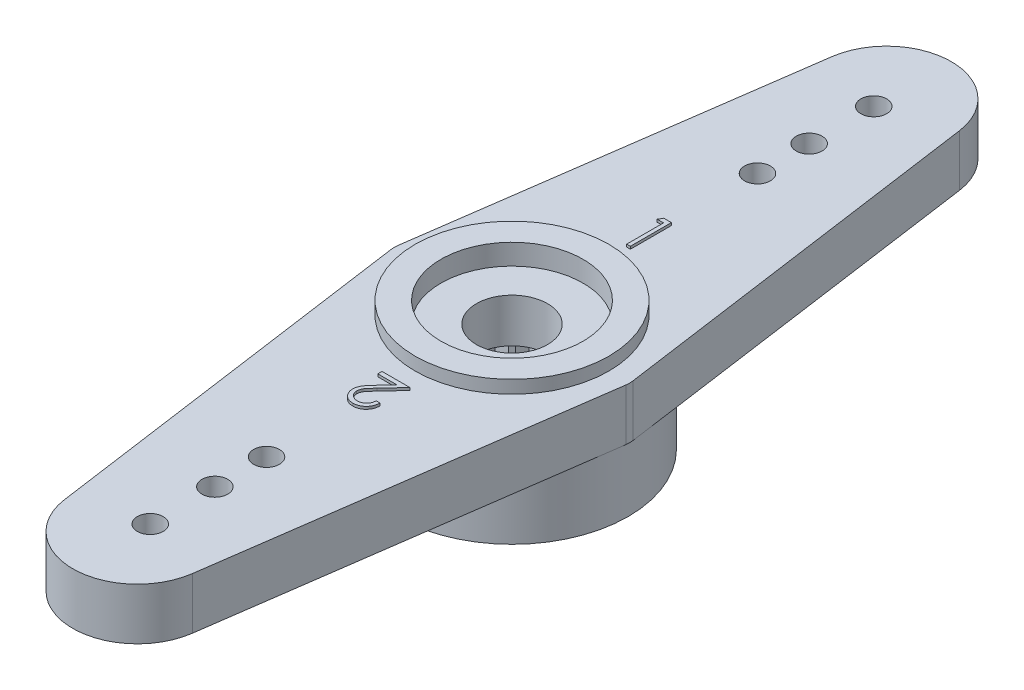
from build123d import *

# Parameters (mm, degrees)
SKETCH1_R           = 0.5
SKETCH1_R_2         = 1.375
BOSS_EXTRUDE1_DEPTH = 2
SKETCH2_R           = 3.75
SKETCH2_R_2         = 2.75
BOSS_EXTRUDE2_DEPTH = 0.5
SKETCH3_R           = 2.75
SKETCH3_R_2         = 1.375
CUT_EXTRUDE1_DEPTH  = 0.8
SKETCH4_R           = 4.5
SKETCH4_R_2         = 2.5
BOSS_EXTRUDE3_DEPTH = 2.5
CUT_EXTRUDE3_DEPTH  = 2.5
BOSS_EXTRUDE4_DEPTH = 0.1
FILLET1_R           = 1


with BuildPart() as part:
    # Sketch1 → Boss-Extrude1 (new body)
    with BuildSketch(Plane(origin=(0, 0, 0), x_dir=(1, 0, 0), z_dir=(0, 1, 0))):
        with BuildLine():
            Line((-4, 4), (-2.475677962, 14.847877319))
            ThreePointArc((-2.475677962, 14.847877319), (0, 17), (2.475677962, 14.847877319))
            Line((2.475677962, 14.847877319), (4, 4))
            Line((4, 4), (4.562072005, 0))
            Line((4.562072005, 0), (4, -4))
            Line((4, -4), (2.475677962, -14.847877319))
            ThreePointArc((2.475677962, -14.847877319), (0, -17), (-2.475677962, -14.847877319))
            Line((-2.475677962, -14.847877319), (-4, -4))
            Line((-4, -4), (-4.562072005, 0))
            Line((-4.562072005, 0), (-4, 4))
        make_face()
        with Locations((0, 14)):
            Circle(SKETCH1_R, mode=Mode.SUBTRACT)
        with Locations((0, 11.5)):
            Circle(SKETCH1_R, mode=Mode.SUBTRACT)
        with Locations((0, 9.5)):
            Circle(SKETCH1_R, mode=Mode.SUBTRACT)
        with Locations((0, -14)):
            Circle(SKETCH1_R, mode=Mode.SUBTRACT)
        with Locations((0, -11.5)):
            Circle(SKETCH1_R, mode=Mode.SUBTRACT)
        with Locations((0, -9.5)):
            Circle(SKETCH1_R, mode=Mode.SUBTRACT)
        Circle(SKETCH1_R_2, mode=Mode.SUBTRACT)
    extrude(amount=BOSS_EXTRUDE1_DEPTH)

    # Sketch2 → Boss-Extrude2 (add)
    with BuildSketch(Plane(origin=(0, 2, 0), x_dir=(1, 0, 0), z_dir=(0, 1, 0))):
        Circle(SKETCH2_R)
        Circle(SKETCH2_R_2, mode=Mode.SUBTRACT)
    extrude(amount=BOSS_EXTRUDE2_DEPTH)

    # Sketch3 → Cut-Extrude1 (cut)
    with BuildSketch(Plane(origin=(0, 2.5, 0), x_dir=(1, 0, 0), z_dir=(0, 1, 0))):
        Circle(SKETCH3_R)
        Circle(SKETCH3_R_2, mode=Mode.SUBTRACT)
    extrude(amount=-CUT_EXTRUDE1_DEPTH, mode=Mode.SUBTRACT)

    # Sketch4 → Boss-Extrude3 (add)
    with BuildSketch(Plane.XZ):
        Circle(SKETCH4_R)
        Circle(SKETCH4_R_2, mode=Mode.SUBTRACT)
    extrude(amount=BOSS_EXTRUDE3_DEPTH)

    # Sketch5 → Cut-Extrude3 (cut)
    with BuildSketch(Plane.XZ.offset(2.5)):
        with BuildLine():
            Line((0.299038106, 2.482050808), (0, 3))
            Line((0, 3), (-0.299038106, 2.482050808))
            ThreePointArc((-0.299038106, 2.482050808), (0, 2.5), (0.299038106, 2.482050808))
        make_face()
        with BuildLine():
            ThreePointArc((-1.051398019, 2.268162738), (-0.772542486, 2.377641291), (-0.482593741, 2.452978451))
            Line((-0.482593741, 2.452978451), (-0.927050983, 2.853169549))
            Line((-0.927050983, 2.853169549), (-1.051398019, 2.268162738))
        make_face()
        with BuildLine():
            Line((0.927050983, 2.853169549), (0.482593741, 2.452978451))
            ThreePointArc((0.482593741, 2.452978451), (0.772542486, 2.377641291), (1.051398019, 2.268162738))
            Line((1.051398019, 2.268162738), (0.927050983, 2.853169549))
        make_face()
        with BuildLine():
            ThreePointArc((-1.70083977, 1.832251096), (-1.469463131, 2.022542486), (-1.216985951, 2.183791473))
            Line((-1.216985951, 2.183791473), (-1.763355757, 2.427050983))
            Line((-1.763355757, 2.427050983), (-1.70083977, 1.832251096))
        make_face()
        with BuildLine():
            Line((1.763355757, 2.427050983), (1.216985951, 2.183791473))
            ThreePointArc((1.216985951, 2.183791473), (1.469463131, 2.022542486), (1.70083977, 1.832251096))
            Line((1.70083977, 1.832251096), (1.763355757, 2.427050983))
        make_face()
        with BuildLine():
            ThreePointArc((-2.183791473, 1.216985951), (-2.022542486, 1.469463131), (-1.832251096, 1.70083977))
            Line((-1.832251096, 1.70083977), (-2.427050983, 1.763355757))
            Line((-2.427050983, 1.763355757), (-2.183791473, 1.216985951))
        make_face()
        with BuildLine():
            Line((2.427050983, 1.763355757), (1.832251096, 1.70083977))
            ThreePointArc((1.832251096, 1.70083977), (2.022542486, 1.469463131), (2.183791473, 1.216985951))
            Line((2.183791473, 1.216985951), (2.427050983, 1.763355757))
        make_face()
        with BuildLine():
            ThreePointArc((-2.452978451, 0.482593741), (-2.377641291, 0.772542486), (-2.268162738, 1.051398019))
            Line((-2.268162738, 1.051398019), (-2.853169549, 0.927050983))
            Line((-2.853169549, 0.927050983), (-2.452978451, 0.482593741))
        make_face()
        with BuildLine():
            Line((2.853169549, 0.927050983), (2.268162738, 1.051398019))
            ThreePointArc((2.268162738, 1.051398019), (2.377641291, 0.772542486), (2.452978451, 0.482593741))
            Line((2.452978451, 0.482593741), (2.853169549, 0.927050983))
        make_face()
        with BuildLine():
            ThreePointArc((-2.482050808, -0.299038106), (-2.5, 0), (-2.482050808, 0.299038106))
            Line((-2.482050808, 0.299038106), (-3, 0))
            Line((-3, 0), (-2.482050808, -0.299038106))
        make_face()
        with BuildLine():
            Line((3, 0), (2.482050808, 0.299038106))
            ThreePointArc((2.482050808, 0.299038106), (2.5, 0), (2.482050808, -0.299038106))
            Line((2.482050808, -0.299038106), (3, 0))
        make_face()
        with BuildLine():
            ThreePointArc((-2.268162738, -1.051398019), (-2.377641291, -0.772542486), (-2.452978451, -0.482593741))
            Line((-2.452978451, -0.482593741), (-2.853169549, -0.927050983))
            Line((-2.853169549, -0.927050983), (-2.268162738, -1.051398019))
        make_face()
        with BuildLine():
            Line((2.853169549, -0.927050983), (2.452978451, -0.482593741))
            ThreePointArc((2.452978451, -0.482593741), (2.377641291, -0.772542486), (2.268162738, -1.051398019))
            Line((2.268162738, -1.051398019), (2.853169549, -0.927050983))
        make_face()
        with BuildLine():
            ThreePointArc((-1.832251096, -1.70083977), (-2.022542486, -1.469463131), (-2.183791473, -1.216985951))
            Line((-2.183791473, -1.216985951), (-2.427050983, -1.763355757))
            Line((-2.427050983, -1.763355757), (-1.832251096, -1.70083977))
        make_face()
        with BuildLine():
            Line((2.427050983, -1.763355757), (2.183791473, -1.216985951))
            ThreePointArc((2.183791473, -1.216985951), (2.022542486, -1.469463131), (1.832251096, -1.70083977))
            Line((1.832251096, -1.70083977), (2.427050983, -1.763355757))
        make_face()
        with BuildLine():
            ThreePointArc((-1.216985951, -2.183791473), (-1.469463131, -2.022542486), (-1.70083977, -1.832251096))
            Line((-1.70083977, -1.832251096), (-1.763355757, -2.427050983))
            Line((-1.763355757, -2.427050983), (-1.216985951, -2.183791473))
        make_face()
        with BuildLine():
            Line((1.763355757, -2.427050983), (1.70083977, -1.832251096))
            ThreePointArc((1.70083977, -1.832251096), (1.469463131, -2.022542486), (1.216985951, -2.183791473))
            Line((1.216985951, -2.183791473), (1.763355757, -2.427050983))
        make_face()
        with BuildLine():
            ThreePointArc((-0.482593741, -2.452978451), (-0.772542486, -2.377641291), (-1.051398019, -2.268162738))
            Line((-1.051398019, -2.268162738), (-0.927050983, -2.853169549))
            Line((-0.927050983, -2.853169549), (-0.482593741, -2.452978451))
        make_face()
        with BuildLine():
            Line((0.927050983, -2.853169549), (1.051398019, -2.268162738))
            ThreePointArc((1.051398019, -2.268162738), (0.772542486, -2.377641291), (0.482593741, -2.452978451))
            Line((0.482593741, -2.452978451), (0.927050983, -2.853169549))
        make_face()
        with BuildLine():
            ThreePointArc((0.299038106, -2.482050808), (0, -2.5), (-0.299038106, -2.482050808))
            Line((-0.299038106, -2.482050808), (0, -3))
            Line((0, -3), (0.299038106, -2.482050808))
        make_face()
    extrude(amount=-CUT_EXTRUDE3_DEPTH, mode=Mode.SUBTRACT)

    # Sketch6 → Boss-Extrude4 (add)
    with BuildSketch(Plane(origin=(0, 2, 0), x_dir=(1, 0, 0), z_dir=(0, 1, 0))):
        Polygon((-0.212111879, 6.0875), (0.081410256, 6.0875), (0.081410256, 4.5), (-0.061057692, 4.5), (-0.061057692, 5.924679487), (-0.305288462, 5.924679487), align=None)
        with BuildLine():
            Line((0.34599359, -5.599038462), (0.488461538, -5.599038462))
            add(Edge.make_bspline(
                [(0.488461538, -5.599038462), (0.487533166, -5.617939279), (0.485709868, -5.655059981), (0.477167658, -5.709180577), (0.46495614, -5.760917347), (0.447649569, -5.809826741), (0.426277468, -5.856493025), (0.40011183, -5.900296523), (0.369710466, -5.941671981), (0.335129148, -5.979836023), (0.29760523, -6.014722729), (0.25736354, -6.045167992), (0.214817686, -6.070596953), (0.170336692, -6.091970581), (0.123406123, -6.107994605), (0.074474582, -6.119889389), (0.023320904, -6.127044708), (-0.011531495, -6.12781392), (-0.029256811, -6.128205128)],
                knots=[0, 0, 0, 0, 5.6734e-05, 0.000111424, 0.000164104, 0.000216001, 0.000266797, 0.000317845, 0.000368792, 0.000420582, 0.000472116, 0.000522298, 0.000571655, 0.000620588, 0.000670069, 0.000720126, 0.000771487, 0.000824641, 0.000824641, 0.000824641, 0.000824641], degree=3))
            add(Edge.make_bspline(
                [(-0.029256811, -6.128205128), (-0.046665234, -6.127800921), (-0.080872163, -6.127006668), (-0.130775818, -6.120083276), (-0.178395874, -6.109473794), (-0.223192652, -6.093752213), (-0.265625894, -6.074025069), (-0.305170205, -6.049491779), (-0.342781809, -6.021313179), (-0.376614792, -5.988075137), (-0.407694469, -5.952610063), (-0.434483272, -5.914733662), (-0.457553999, -5.875568297), (-0.476436669, -5.834808029), (-0.490750572, -5.792320125), (-0.501355803, -5.748511928), (-0.507418326, -5.702877864), (-0.508343658, -5.671985787), (-0.508814103, -5.656280048)],
                knots=[0, 0, 0, 0, 5.2201e-05, 0.000102573, 0.000150864, 0.000198334, 0.000244711, 0.000290961, 0.00033771, 0.00038539, 0.000432956, 0.000479018, 0.000524342, 0.000569163, 0.000613513, 0.000658635, 0.000704195, 0.000751313, 0.000751313, 0.000751313, 0.000751313], degree=3))
            add(Edge.make_bspline(
                [(-0.508814103, -5.656280048), (-0.508046075, -5.634169433), (-0.506523497, -5.590336212), (-0.493499653, -5.525922188), (-0.473157884, -5.463514275), (-0.448668396, -5.413285287), (-0.423956394, -5.372815356), (-0.401709565, -5.339477962), (-0.37551786, -5.303591998), (-0.345605049, -5.265012215), (-0.311455992, -5.224243848), (-0.273957876, -5.180455113), (-0.232142299, -5.134455695), (-0.202819526, -5.103017004), (-0.1876252, -5.086726262)],
                knots=[0, 0, 0, 0, 6.6275e-05, 0.000131387, 0.000196351, 0.000262772, 0.00029844, 0.000338571, 0.000382971, 0.000431697, 0.000484995, 0.000542495, 0.000604638, 0.000671469, 0.000671469, 0.000671469, 0.000671469], degree=3))
            Line((-0.1876252, -5.086726262), (0.209567808, -4.662820513))
            Line((0.209567808, -4.662820513), (-0.529166667, -4.662820513))
            Line((-0.529166667, -4.662820513), (-0.529166667, -4.5))
            Line((-0.529166667, -4.5), (0.549519231, -4.5))
            Line((0.549519231, -4.5), (-0.066145833, -5.15700621))
            add(Edge.make_bspline(
                [(-0.066145833, -5.15700621), (-0.081136472, -5.172652803), (-0.10993042, -5.202706705), (-0.15063927, -5.246597776), (-0.187261175, -5.287268318), (-0.219820431, -5.324898551), (-0.248343825, -5.359275147), (-0.272740096, -5.390667508), (-0.293117072, -5.418806234), (-0.31471242, -5.451862432), (-0.335305017, -5.492269991), (-0.353403803, -5.541401752), (-0.364360562, -5.592090897), (-0.36568164, -5.626334746), (-0.366346154, -5.643559696)],
                knots=[0, 0, 0, 0, 6.5005e-05, 0.000124862, 0.000179583, 0.000229184, 0.000274136, 0.000313574, 0.000348435, 0.000378338, 0.000431957, 0.000484068, 0.000535086, 0.000586722, 0.000586722, 0.000586722, 0.000586722], degree=3))
            add(Edge.make_bspline(
                [(-0.366346154, -5.643559696), (-0.366060761, -5.654392812), (-0.365498307, -5.675742806), (-0.360440353, -5.707024672), (-0.353009214, -5.737316681), (-0.341555532, -5.766244292), (-0.327794356, -5.794376458), (-0.310213439, -5.820857871), (-0.290123068, -5.846591221), (-0.266819222, -5.87069413), (-0.241235929, -5.892776139), (-0.214204803, -5.912335573), (-0.185607306, -5.928681993), (-0.155562618, -5.94208205), (-0.124154868, -5.952593749), (-0.091323211, -5.959877459), (-0.057158391, -5.964450586), (-0.033829626, -5.965069336), (-0.021942608, -5.965384615)],
                knots=[0, 0, 0, 0, 3.2476e-05, 6.4004e-05, 9.4855e-05, 0.000125861, 0.000157149, 0.000188638, 0.00022102, 0.000254982, 0.000289027, 0.000322298, 0.000354918, 0.000387659, 0.000420845, 0.000454096, 0.000488413, 0.000524066, 0.000524066, 0.000524066, 0.000524066], degree=3))
            add(Edge.make_bspline(
                [(-0.021942608, -5.965384615), (-0.009524809, -5.965073193), (0.014861697, -5.96446161), (0.050589548, -5.959826318), (0.084911307, -5.952806404), (0.117298087, -5.94163076), (0.148427683, -5.928551128), (0.177505966, -5.911615305), (0.20534978, -5.892263509), (0.231399316, -5.869700543), (0.255124815, -5.844230354), (0.276708114, -5.816506502), (0.294995857, -5.786037502), (0.311229702, -5.753554464), (0.323645389, -5.718164946), (0.334259911, -5.680734442), (0.341970146, -5.640728907), (0.344630167, -5.613166089), (0.34599359, -5.599038462)],
                knots=[0, 0, 0, 0, 3.7241e-05, 7.3135e-05, 0.000107939, 0.000142131, 0.000175745, 0.000209075, 0.000242865, 0.000277359, 0.000312231, 0.000347151, 0.000382547, 0.000418672, 0.000455894, 0.000494859, 0.000535336, 0.000577899, 0.000577899, 0.000577899, 0.000577899], degree=3))
        make_face()
    extrude(amount=BOSS_EXTRUDE4_DEPTH)

    # Fillet1
    fillet1_edges = [part.edges().sort_by_distance(p)[0] for p in [
        (-4.562072005, 1, 0),
        (4.562072005, 1, 0),
    ]]
    fillet(fillet1_edges, radius=FILLET1_R)


solid = part.part
